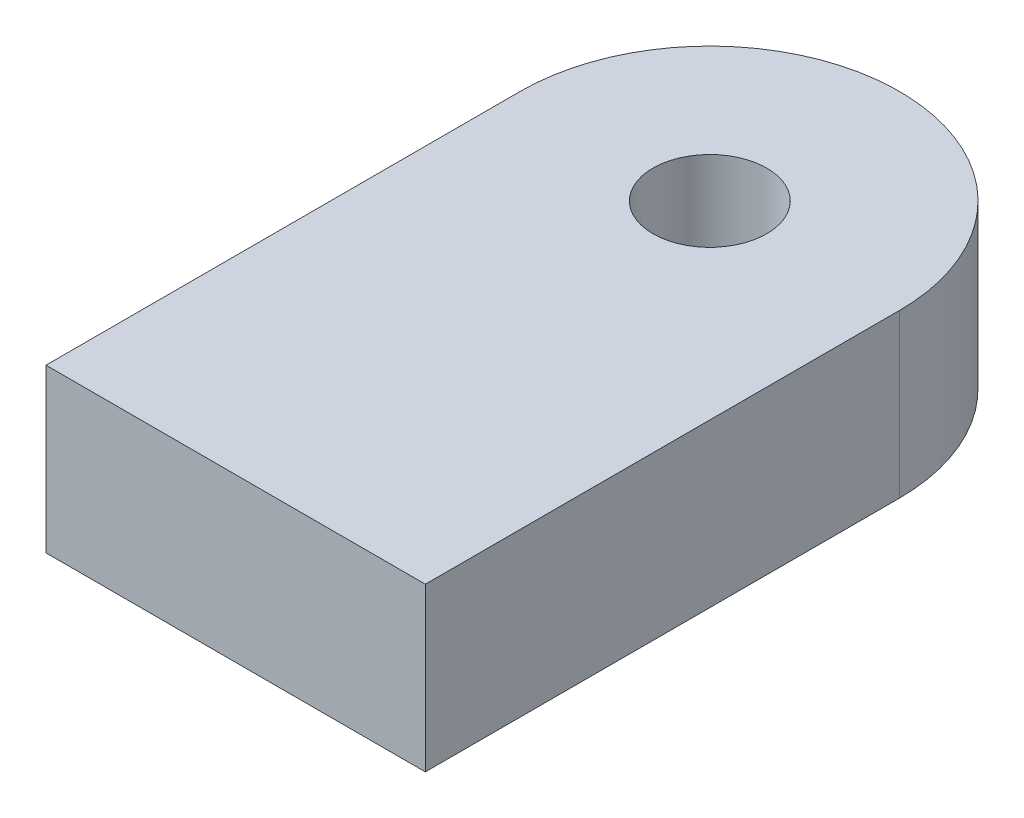
from build123d import *

# Parameters (mm, degrees)
SKETCH1_R           = 2.1
BOSS_EXTRUDE1_DEPTH = 6


with BuildPart() as part:
    # Sketch1 → Boss-Extrude1 (new body)
    with BuildSketch(Plane(origin=(0, 0, 0), x_dir=(1, 0, 0), z_dir=(0, 1, 0))):
        with BuildLine():
            Line((-7, -8.75), (7, -8.75))
            Line((7, -8.75), (7, 8.75))
            ThreePointArc((7, 8.75), (0, 15.75), (-7, 8.75))
            Line((-7, 8.75), (-7, -8.75))
        make_face()
        with Locations((0, 8.75)):
            Circle(SKETCH1_R, mode=Mode.SUBTRACT)
    extrude(amount=BOSS_EXTRUDE1_DEPTH)


solid = part.part
